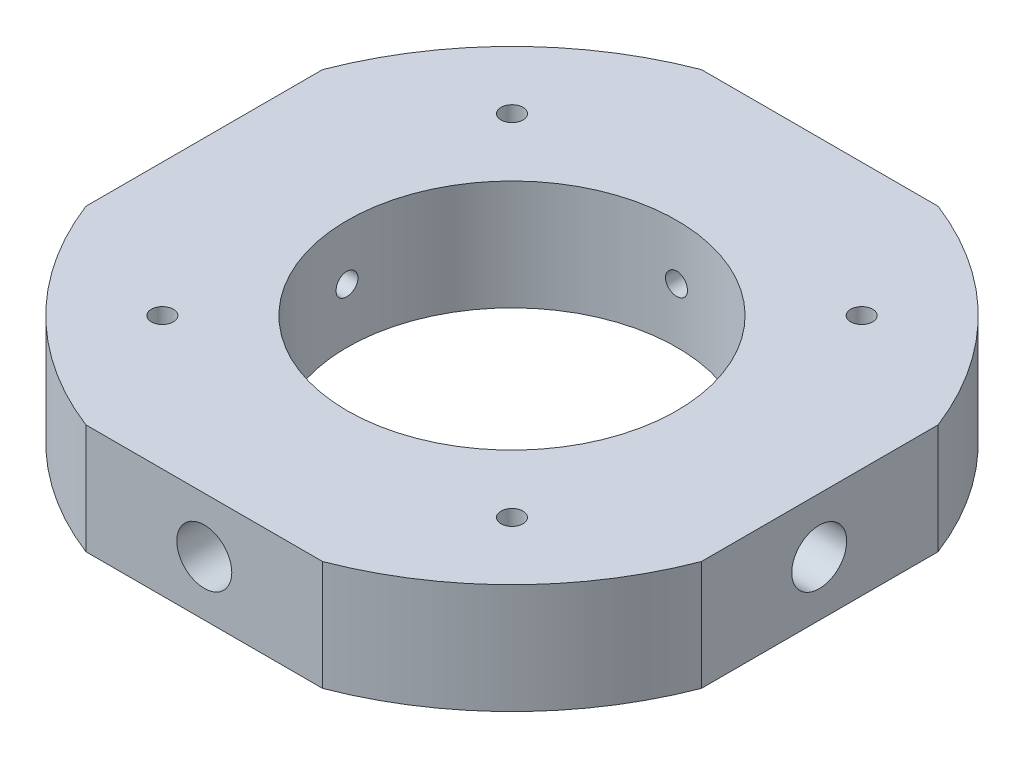
from build123d import *

# Parameters (mm, degrees)
SKETCH1_R           = 30
SKETCH1_R_2         = 15
BOSS_EXTRUDE1_DEPTH = 10
CUT_EXTRUDE1_DEPTH  = 43
SKETCH4_R           = 1
CUT_EXTRUDE3_DEPTH  = 43
SKETCH5_R           = 1
CUT_EXTRUDE4_DEPTH  = 70
SKETCH6_R           = 1
CUT_EXTRUDE5_DEPTH  = 70
SKETCH8_R           = 2.5
CUT_EXTRUDE6_DEPTH  = 4
SKETCH9_R           = 2.5
SKETCH9_R_2         = 1
CUT_EXTRUDE7_DEPTH  = 4
SKETCH10_R          = 2.5
CUT_EXTRUDE8_DEPTH  = 4
SKETCH11_R          = 2.5
CUT_EXTRUDE9_DEPTH  = 4


with BuildPart() as part:
    # Sketch1 → Boss-Extrude1 (new body)
    with BuildSketch(Plane(origin=(0, 0, 0), x_dir=(1, 0, 0), z_dir=(0, 1, 0))):
        Circle(SKETCH1_R)
        Circle(SKETCH1_R_2, mode=Mode.SUBTRACT)
    extrude(amount=BOSS_EXTRUDE1_DEPTH)

    # Sketch2 → Cut-Extrude1 (cut)
    with BuildSketch(Plane(origin=(0, 10, 0), x_dir=(1, 0, 0), z_dir=(0, 1, 0))):
        with BuildLine():
            ThreePointArc((10.770329614, 28), (0, 30), (-10.770329614, 28))
            Line((-10.770329614, 28), (10.770329614, 28))
        make_face()
        with BuildLine():
            Line((-28, -10.770329614), (-28, 10.770329614))
            ThreePointArc((-28, 10.770329614), (-30, 0), (-28, -10.770329614))
        make_face()
        with BuildLine():
            ThreePointArc((30, 0), (29.495762408, 5.477225575), (28, 10.770329614))
            Line((28, 10.770329614), (28, -10.770329614))
            ThreePointArc((28, -10.770329614), (29.495762408, -5.477225575), (30, 0))
        make_face()
        with BuildLine():
            Line((10.770329614, -28), (-10.770329614, -28))
            ThreePointArc((-10.770329614, -28), (0, -30), (10.770329614, -28))
        make_face()
    extrude(amount=-CUT_EXTRUDE1_DEPTH, mode=Mode.SUBTRACT)

    # Sketch4 → Cut-Extrude3 (cut)
    with BuildSketch(Plane(origin=(0, 10, 0), x_dir=(1, 0, 0), z_dir=(0, 1, 0))):
        with Locations((15.909902577, -15.909902577)):
            Circle(SKETCH4_R)
        with Locations((-15.909902577, -15.909902577)):
            Circle(SKETCH4_R)
        with Locations((-15.909902577, 15.909902577)):
            Circle(SKETCH4_R)
        with Locations((15.909902577, 15.909902577)):
            Circle(SKETCH4_R)
    extrude(amount=-CUT_EXTRUDE3_DEPTH, mode=Mode.SUBTRACT)

    # Sketch5 → Cut-Extrude4 (cut)
    with BuildSketch(Plane(origin=(0, 0, -28), x_dir=(-1, 0, 0), z_dir=(0, 0, -1))):
        with Locations((0, 5)):
            Circle(SKETCH5_R)
    extrude(amount=-CUT_EXTRUDE4_DEPTH, mode=Mode.SUBTRACT)

    # Sketch6 → Cut-Extrude5 (cut)
    with BuildSketch(Plane(origin=(28, 0, 0), x_dir=(0, 0, -1), z_dir=(1, 0, 0))):
        with Locations((-0.045783142, 5)):
            Circle(SKETCH6_R)
    extrude(amount=-CUT_EXTRUDE5_DEPTH, mode=Mode.SUBTRACT)

    # Sketch8 → Cut-Extrude6 (cut)
    with BuildSketch(Plane(origin=(0, 0, -28), x_dir=(-1, 0, 0), z_dir=(0, 0, -1))):
        with Locations((0, 5)):
            Circle(SKETCH8_R)
    extrude(amount=-CUT_EXTRUDE6_DEPTH, mode=Mode.SUBTRACT)

    # Sketch9 → Cut-Extrude7 (cut)
    with BuildSketch(Plane(origin=(28, 0, 0), x_dir=(0, 0, -1), z_dir=(1, 0, 0))):
        with Locations((-0.045783142, 5)):
            Circle(SKETCH9_R)
        with Locations((-0.045783142, 5)):
            Circle(SKETCH9_R_2, mode=Mode.SUBTRACT)
    extrude(amount=-CUT_EXTRUDE7_DEPTH, mode=Mode.SUBTRACT)

    # Sketch10 → Cut-Extrude8 (cut)
    with BuildSketch(Plane.XY.offset(28)):
        with Locations((0, 5)):
            Circle(SKETCH10_R)
    extrude(amount=-CUT_EXTRUDE8_DEPTH, mode=Mode.SUBTRACT)

    # Sketch11 → Cut-Extrude9 (cut)
    with BuildSketch(Plane.ZY.offset(28)):
        with Locations((0.045783142, 5)):
            Circle(SKETCH11_R)
    extrude(amount=-CUT_EXTRUDE9_DEPTH, mode=Mode.SUBTRACT)


solid = part.part
